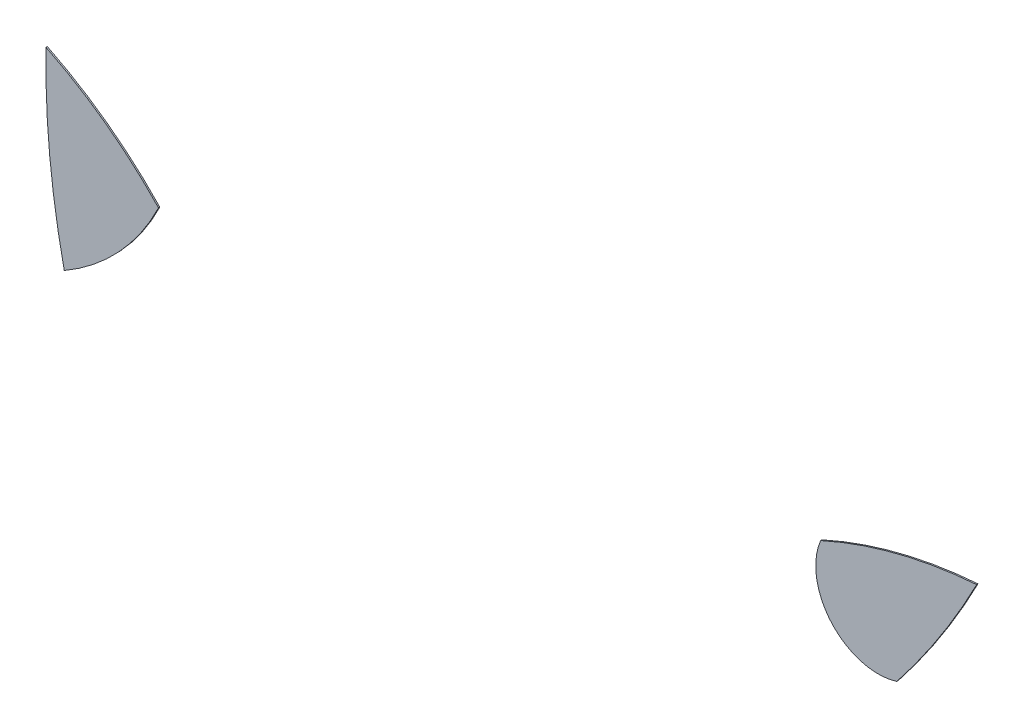
from build123d import *

# Parameters (mm, degrees)
SALIENTE_EXTRUIR1_DEPTH   = 0.1
SALIENTE_EXTRUIR1_2_DEPTH = 0.1


with BuildPart() as part:
    # Model → Saliente-Extruir1 (new body)
    with BuildSketch(Plane.XY):
        with BuildLine():
            ThreePointArc((56.7853139, 83.347070157), (60.010011193, 87.860883314), (62.79150044, 92.660518656))
            ThreePointArc((62.79150044, 92.660518656), (56.791217612, 91.679294852), (51.055795467, 89.661591454))
            ThreePointArc((51.055795467, 89.661591454), (51.905913993, 84.6763346), (56.7853139, 83.347070157))
        make_face()
    extrude(amount=SALIENTE_EXTRUIR1_DEPTH)


with BuildPart() as body_2:
    # Model → Saliente-Extruir1 2 (new body)
    with BuildSketch(Plane.XY):
        with BuildLine():
            ThreePointArc((1.252486962, 86.430906166), (-2.701090718, 89.9218159), (-7.20849956, 92.660518656))
            ThreePointArc((-7.20849956, 92.660518656), (-6.926809654, 85.693416928), (-5.833511394, 78.806868111))
            ThreePointArc((-5.833511394, 78.806868111), (-1.718584289, 82.087321015), (1.252486962, 86.430906166))
        make_face()
    extrude(amount=SALIENTE_EXTRUIR1_2_DEPTH)


solid = Compound([part.part, body_2.part])
